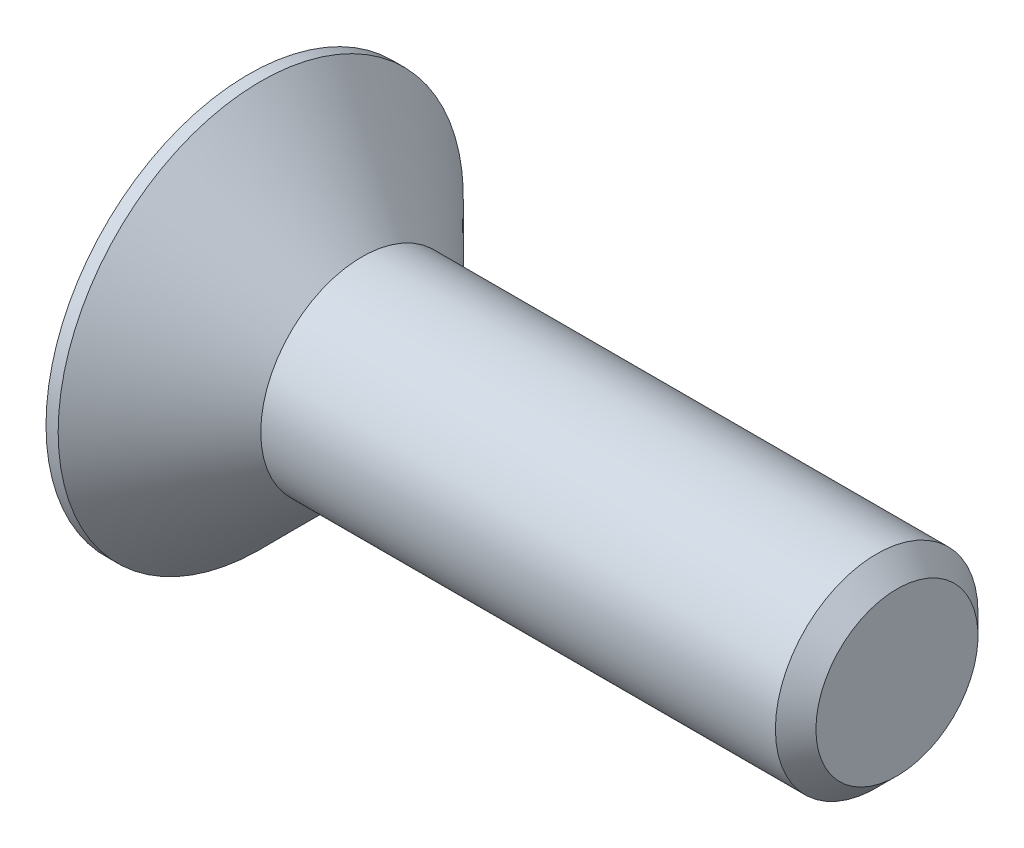
from build123d import *

# Parameters (mm, degrees)
CUT_EXTRUDE1_DEPTH = 0.8


with BuildPart() as part:
    # Sketch2 → Revolve1 (revolve)
    with BuildSketch(Plane.XY):
        Polygon((0, 0), (0, 2.5), (0.15, 2.5), (1.4, 1.25), (7.75, 1.25), (8, 1), (8, 0), align=None)
    revolve(axis=Axis((-2.281841559, 0, 0), (1, 0, 0)))

    # Sketch3 → Cut-Extrude1 (cut)
    with BuildSketch(Plane.ZY):
        Polygon((0.433012702, -0.75), (0.866025404, 0), (0.433012702, 0.75), (-0.433012702, 0.75), (-0.866025404, 0), (-0.433012702, -0.75), align=None)
    extrude(amount=-CUT_EXTRUDE1_DEPTH, mode=Mode.SUBTRACT)


solid = part.part
